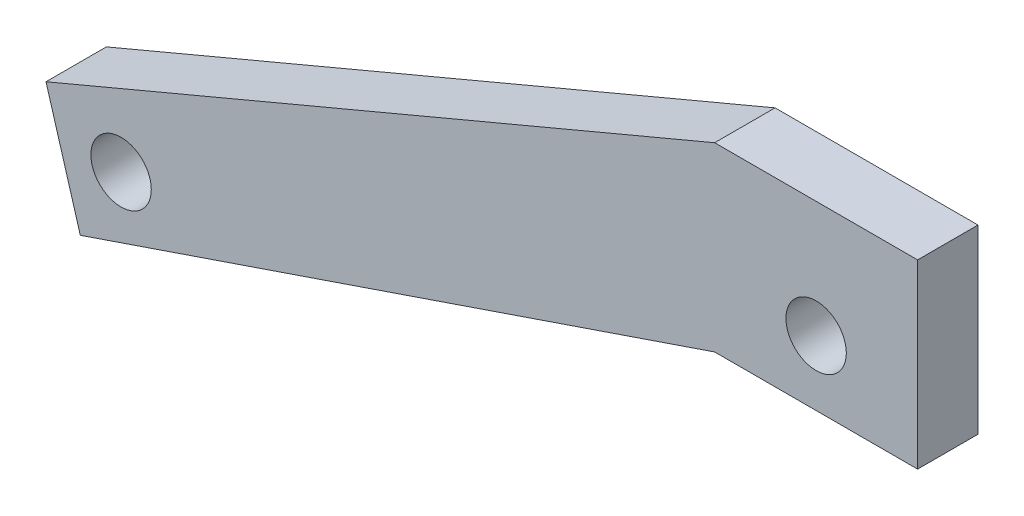
from build123d import *

# Parameters (mm, degrees)
SKETCH1_R           = 4.762500002
BOSS_EXTRUDE1_DEPTH = 9.525


with BuildPart() as part:
    # Sketch1 → Boss-Extrude1 (new body)
    with BuildSketch(Plane.XY):
        Polygon((-111.230275822, 107.869299126), (-216.661395476, 63.481453953), (-211.250903159, 45.215938004), (-111.230275822, 79.294299126), (-79.230275822, 79.294299126), (-79.230275822, 107.869299126), align=None)
        with Locations((-95.230295648, 89.516896037)):
            Circle(SKETCH1_R, mode=Mode.SUBTRACT)
        with Locations((-204.823391343, 57.053942137)):
            Circle(SKETCH1_R, mode=Mode.SUBTRACT)
    extrude(amount=BOSS_EXTRUDE1_DEPTH)


solid = part.part
